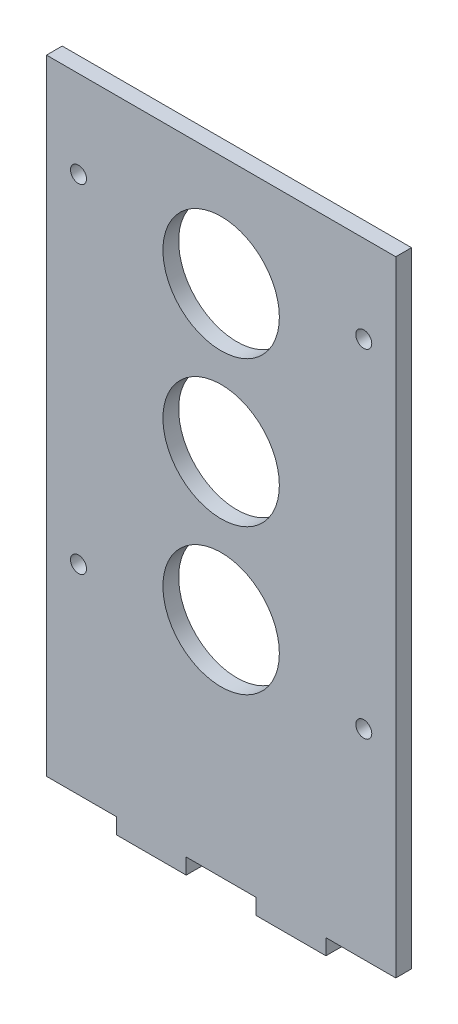
from build123d import *

# Parameters (mm, degrees)
SKETCH1_R           = 1.375
SKETCH1_R_2         = 10
BOSS_EXTRUDE1_DEPTH = 2.7


with BuildPart() as part:
    # Sketch1 → Boss-Extrude1 (new body)
    with BuildSketch(Plane.XY):
        Polygon((30, -47.3), (30, 50), (30, 60), (-30, 60), (-30, 50), (-30, -47.3), (-18, -47.3), (-18, -50), (-6, -50), (-6, -47.3), (6, -47.3), (6, -50), (18, -50), (18, -47.3), align=None)
        with Locations((-24.5, 45)):
            Circle(SKETCH1_R, mode=Mode.SUBTRACT)
        with Locations((24.5, 45)):
            Circle(SKETCH1_R, mode=Mode.SUBTRACT)
        with Locations((-24.5, -13)):
            Circle(SKETCH1_R, mode=Mode.SUBTRACT)
        with Locations((24.5, -13)):
            Circle(SKETCH1_R, mode=Mode.SUBTRACT)
        with Locations((0, 16)):
            Circle(SKETCH1_R_2, mode=Mode.SUBTRACT)
        with Locations((0, 41)):
            Circle(SKETCH1_R_2, mode=Mode.SUBTRACT)
        with Locations((0, -9)):
            Circle(SKETCH1_R_2, mode=Mode.SUBTRACT)
    extrude(amount=BOSS_EXTRUDE1_DEPTH)


solid = part.part
